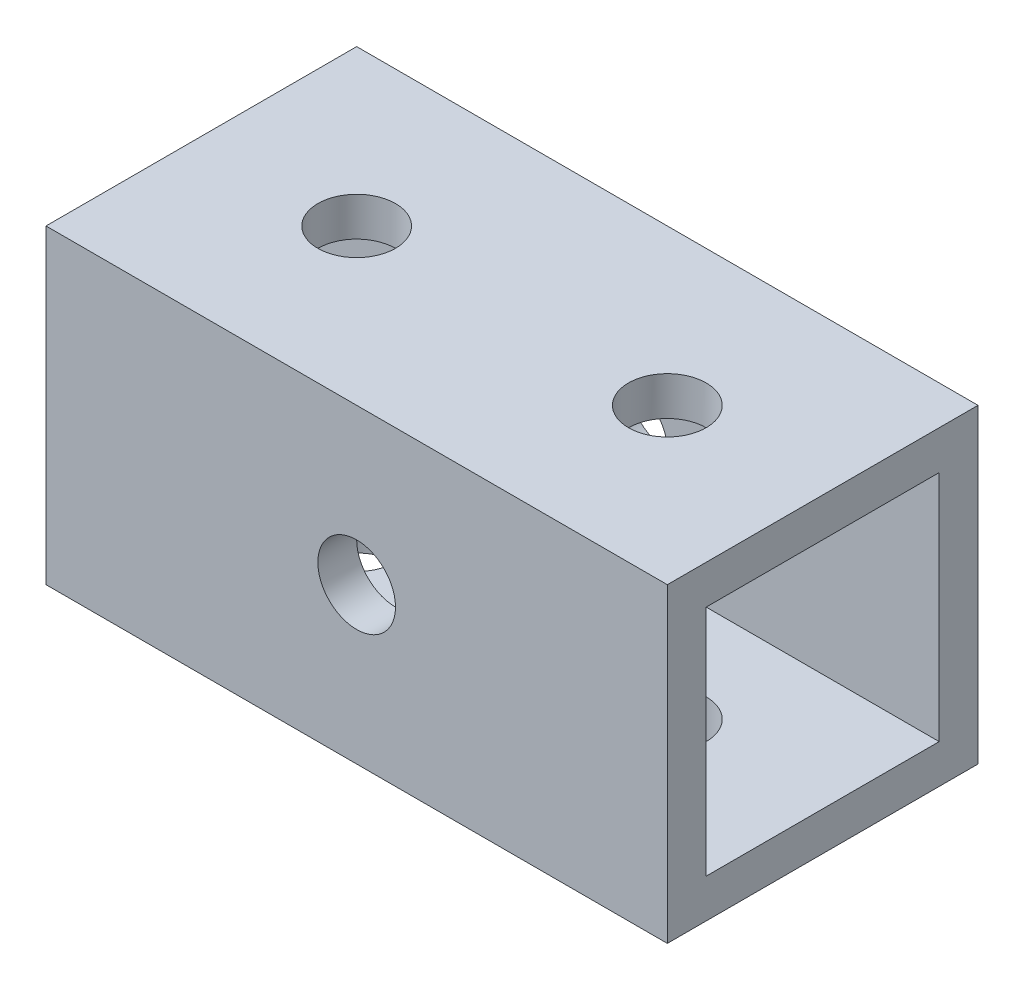
from build123d import *

# Parameters (mm, degrees)
SKETCH1_W          = 25.4
SKETCH1_H          = 25.4
SKETCH1_W_2        = 19.05
SKETCH1_H_2        = 19.05
EXTRUDE1_DEPTH     = 50.8
SKETCH2_R          = 3.175
CUT_EXTRUDE1_DEPTH = 26.4
SKETCH3_R          = 3.175
CUT_EXTRUDE2_DEPTH = 26.4


with BuildPart() as part:
    # Sketch1 → Extrude1 (new body)
    with BuildSketch(Plane(origin=(0, 0, 0), x_dir=(0, 0, -1), z_dir=(1, 0, 0))):
        with Locations((12.7, 12.7)):
            Rectangle(SKETCH1_W, SKETCH1_H)
        with Locations((12.7, 12.7)):
            Rectangle(SKETCH1_W_2, SKETCH1_H_2, mode=Mode.SUBTRACT)
    extrude(amount=EXTRUDE1_DEPTH)

    # Sketch2 → Cut-Extrude1 (cut, through all)
    with BuildSketch(Plane.XY):
        with Locations((25.4, 12.7)):
            Circle(SKETCH2_R)
    extrude(amount=-CUT_EXTRUDE1_DEPTH, mode=Mode.SUBTRACT)

    # Sketch3 → Cut-Extrude2 (cut, through all)
    with BuildSketch(Plane(origin=(0, 25.4, 0), x_dir=(-1, 0, 0), z_dir=(0, 1, 0))):
        with Locations((-38.1, -12.7)):
            Circle(SKETCH3_R)
        with Locations((-12.7, -12.7)):
            Circle(SKETCH3_R)
    extrude(amount=-CUT_EXTRUDE2_DEPTH, mode=Mode.SUBTRACT)


solid = part.part
